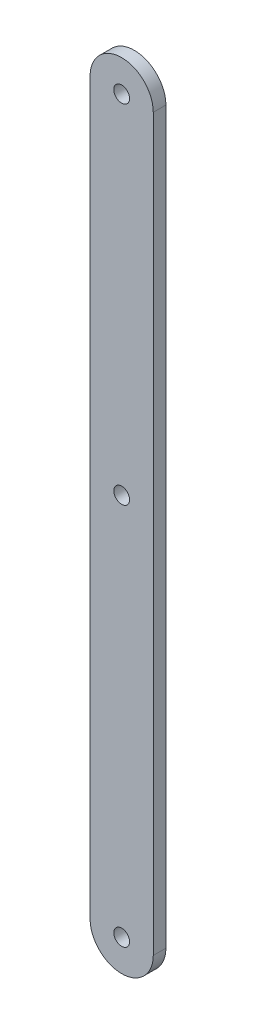
from build123d import *

# Parameters (mm, degrees)
SKETCH1_R           = 1.5875
BOSS_EXTRUDE1_DEPTH = 2.54


with BuildPart() as part:
    # Sketch1 → Boss-Extrude1 (new body)
    with BuildSketch(Plane.XY):
        with BuildLine():
            Line((-6.35, 0), (-6.35, 146.812))
            ThreePointArc((-6.35, 146.812), (0, 153.162), (6.35, 146.812))
            Line((6.35, 146.812), (6.35, 0))
            ThreePointArc((6.35, 0), (0, -6.35), (-6.35, 0))
        make_face()
        Circle(SKETCH1_R, mode=Mode.SUBTRACT)
        with Locations((0, 76.962)):
            Circle(SKETCH1_R, mode=Mode.SUBTRACT)
        with Locations((0, 146.812)):
            Circle(SKETCH1_R, mode=Mode.SUBTRACT)
    extrude(amount=BOSS_EXTRUDE1_DEPTH)


solid = part.part
